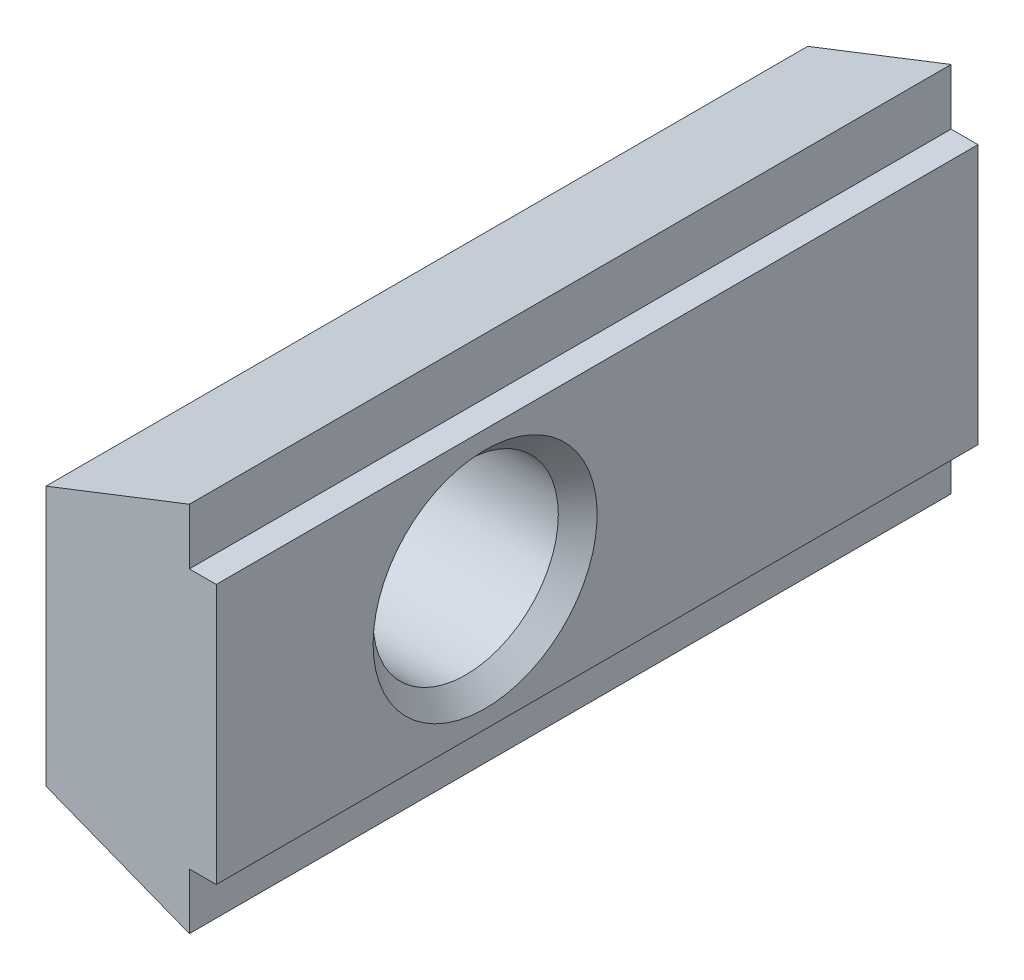
from build123d import *
from build123d.topology import SkipClean

# Parameters (mm, degrees)
EXTRUDE_1_DEPTH      = 8.5
EXTRUDE_1_DEPTH_BACK = 8.5


with BuildPart() as part:
    # ｽｹｯﾁ1 → ﾎﾞｽ - 押し出し1 (new, two sides: drawn at the far end of the back side and taken through both)
    with BuildSketch(Plane.XY.offset(-EXTRUDE_1_DEPTH_BACK)):
        Polygon((0, -2.9), (3.2, -4.15), (3.2, -2.9), (3.8, -2.9), (3.8, 2.9), (3.2, 2.9), (3.2, 4.15), (0, 2.9), align=None)
    extrude(amount=EXTRUDE_1_DEPTH + EXTRUDE_1_DEPTH_BACK)

    # ｽｹｯﾁ2 → ｶｯﾄ - 回転1 (revolve, cut)
    with BuildSketch(Plane.XY.offset(2.5)):
        Polygon((0, 0), (0, 2.5), (0.433, 2.067), (3.367, 2.067), (3.8, 2.5), (3.8, 0), align=None)
    revolve(axis=Axis((3.8, 0, 2.5), (-1, 0, 0)), mode=Mode.SUBTRACT)

    # ｽｹｯﾁ3 → 回転1 (revolve)
    with SkipClean():  # the faces are left unmerged after this step: merging them gives an invalid solid
        with BuildSketch(Plane.XY.offset(-4.25)):
            with BuildLine():
                Line((1.2, 2), (1.2, -2))
                ThreePointArc((1.2, -2), (-0.8, 0), (1.2, 2))
            make_face()
        revolve(axis=Axis((1.2, 3.2, -4.25), (0, -1, 0)))


solid = part.part
